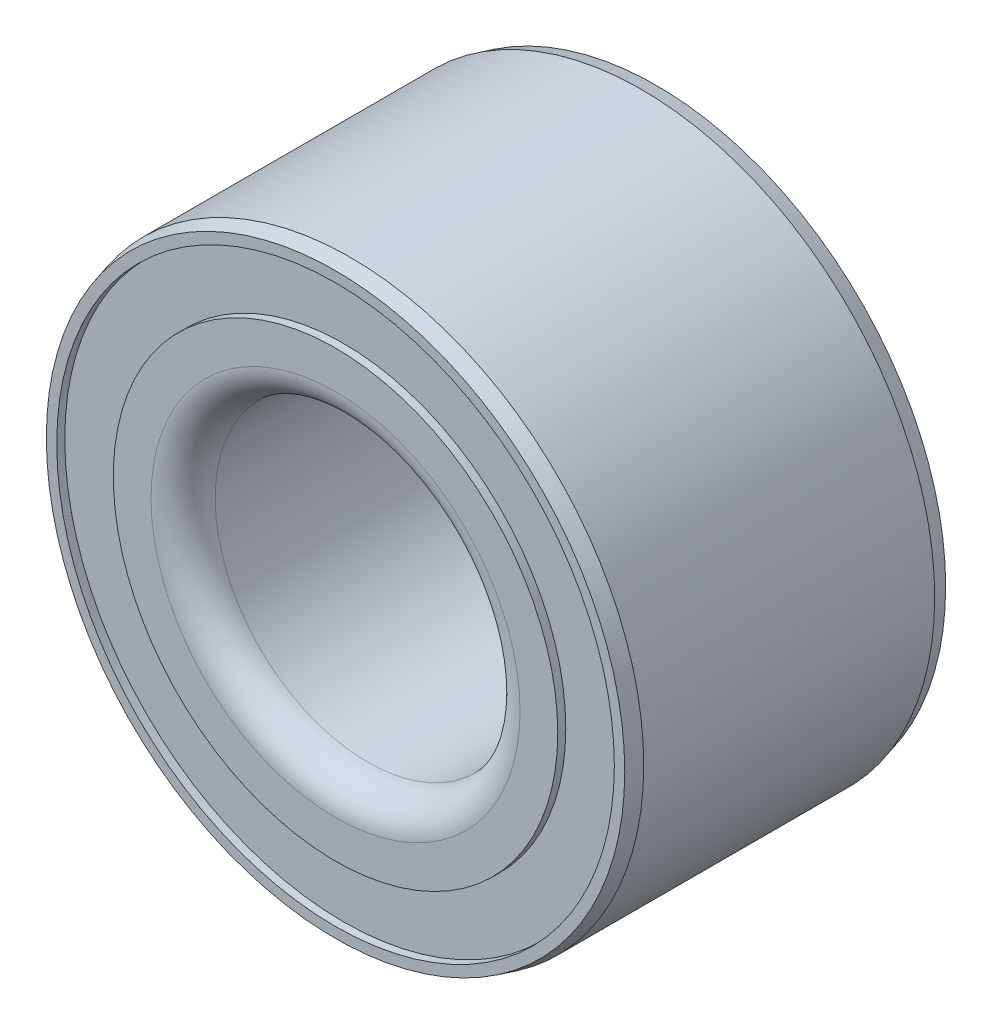
from build123d import *

# Parameters (mm, degrees)
SKETCH1_R             = 36.55
SKETCH1_R_2           = 19
EXTRUDE1_DEPTH        = 40
SKETCH2_R             = 34.75
SKETCH2_R_2           = 27.7
EXTRUDE2_DEPTH        = 1
SKETCH3_R             = 34.75
SKETCH3_R_2           = 27.7
EXTRUDE3_DEPTH        = 1
FILLET1_R             = 4
CHAMFER1_SIZE         = 0.5
CHAMFER1_SIZE2        = 1.866025404
CHAMFER1_PART_2_SIZE  = 0.5
CHAMFER1_PART_2_SIZE2 = 1.866025404


with BuildPart() as part:
    # Sketch1 → Extrude1 (new body)
    with BuildSketch(Plane.XY):
        Circle(SKETCH1_R)
        Circle(SKETCH1_R_2, mode=Mode.SUBTRACT)
    extrude(amount=EXTRUDE1_DEPTH)

    # Sketch2 → Extrude2 (cut)
    with BuildSketch(Plane.XY.offset(40)):
        Circle(SKETCH2_R)
        Circle(SKETCH2_R_2, mode=Mode.SUBTRACT)
    extrude(amount=-EXTRUDE2_DEPTH, mode=Mode.SUBTRACT)

    # Sketch3 → Extrude3 (cut)
    with BuildSketch(Plane(origin=(0, 0, 0), x_dir=(-1, 0, 0), z_dir=(0, 0, -1))):
        Circle(SKETCH3_R)
        Circle(SKETCH3_R_2, mode=Mode.SUBTRACT)
    extrude(amount=-EXTRUDE3_DEPTH, mode=Mode.SUBTRACT)

    # Fillet1
    fillet1_edges = [part.edges().sort_by_distance(p)[0] for p in [
        (-19, 0, 0),
        (-19, 0, 40),
    ]]
    fillet(fillet1_edges, radius=FILLET1_R)

    # Chamfer1
    chamfer1_edges = [part.edges().sort_by_distance(p)[0] for p in [
        (-36.55, 0, 0),
    ]]
    chamfer1_side = [part.faces().sort_by_distance(p)[0] for p in [
        (-35.516209886, 0, 0),
    ]]
    chamfer(chamfer1_edges, length=CHAMFER1_SIZE, length2=CHAMFER1_SIZE2, reference=chamfer1_side[0])

    # Chamfer1 part 2
    chamfer1_part_2_edges = [part.edges().sort_by_distance(p)[0] for p in [
        (-36.55, 0, 40),
    ]]
    chamfer1_part_2_side = [part.faces().sort_by_distance(p)[0] for p in [
        (-35.516209886, 0, 40),
    ]]
    chamfer(chamfer1_part_2_edges, length=CHAMFER1_PART_2_SIZE, length2=CHAMFER1_PART_2_SIZE2, reference=chamfer1_part_2_side[0])


solid = part.part
